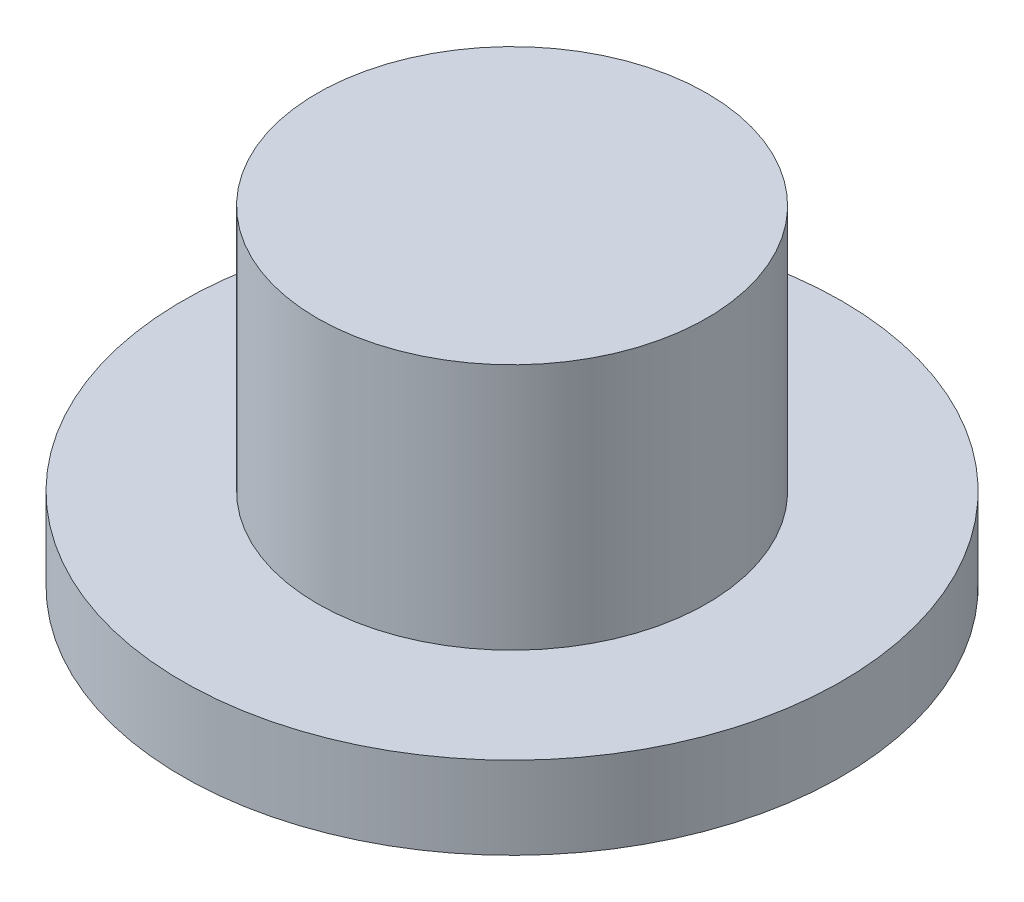
from build123d import *

# Parameters (mm, degrees)
CROQUIS1_R              = 2.365
SALIENTE_EXTRUIR1_DEPTH = 3
CROQUIS2_R              = 4
SALIENTE_EXTRUIR2_DEPTH = 1


with BuildPart() as part:
    # Croquis1 → Saliente-Extruir1 (new body)
    with BuildSketch(Plane(origin=(0, 0, 0), x_dir=(1, 0, 0), z_dir=(0, 1, 0))):
        Circle(CROQUIS1_R)
    extrude(amount=SALIENTE_EXTRUIR1_DEPTH)

    # Croquis2 → Saliente-Extruir2 (add)
    with BuildSketch(Plane.XZ):
        Circle(CROQUIS2_R)
    extrude(amount=SALIENTE_EXTRUIR2_DEPTH)


solid = part.part
